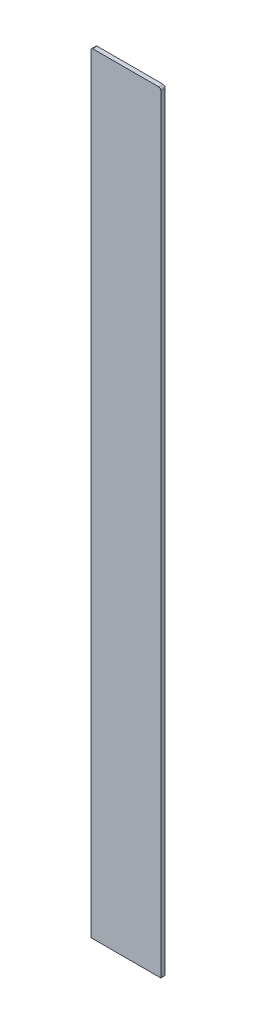
from build123d import *

# Parameters (mm, degrees)
SKETCH1_W           = 1.25
SKETCH1_H           = 80
BOSS_EXTRUDE1_DEPTH = 0.105
FILLET1_R           = 0.25
BOSS_EXTRUDE2_DEPTH = 0.2
BOSS_EXTRUDE3_DEPTH = 0.2


with BuildPart() as part:
    # Sketch1 → Boss-Extrude1 (new body)
    with BuildSketch(Plane.XY):
        with Locations((3.375, -44)):
            Rectangle(SKETCH1_W, SKETCH1_H)
        Polygon((-2.75, -4), (-2.75, -2.75), (-2.75, 2.75), (2.75, 2.75), (2.75, -2.75), (2.75, -4), (4, -4), (4, 4), (-4, 4), (-4, -4), align=None)
        with Locations((-3.375, -44)):
            Rectangle(SKETCH1_W, SKETCH1_H)
    extrude(amount=BOSS_EXTRUDE1_DEPTH)

    # Fillet1
    fillet1_edges = [part.edges().sort_by_distance(p)[0] for p in [
        (2.75, 2.75, 0.0525),
        (-2.75, 2.75, 0.0525),
        (-4, 4, 0.0525),
        (4, 4, 0.0525),
    ]]
    fillet(fillet1_edges, radius=FILLET1_R)

    # Sketch2 → Boss-Extrude2 (add)
    with BuildSketch(Plane(origin=(0, 0, 0), x_dir=(-1, 0, 0), z_dir=(0, 0, -1))):
        with BuildLine():
            Line((2.75, -84), (4, -84))
            Line((4, -84), (4, 3.75))
            ThreePointArc((4, 3.75), (3.926776695, 3.926776695), (3.75, 4))
            Line((3.75, 4), (-3.75, 4))
            ThreePointArc((-3.75, 4), (-3.926776695, 3.926776695), (-4, 3.75))
            Line((-4, 3.75), (-4, -84))
            Line((-4, -84), (-2.75, -84))
            Line((-2.75, -84), (-2.75, 2.5))
            ThreePointArc((-2.75, 2.5), (-2.676776695, 2.676776695), (-2.5, 2.75))
            Line((-2.5, 2.75), (2.5, 2.75))
            ThreePointArc((2.5, 2.75), (2.676776695, 2.676776695), (2.75, 2.5))
            Line((2.75, 2.5), (2.75, -84))
        make_face()
        with BuildLine():
            Line((-2.75, -84), (2.75, -84))
            Line((2.75, -84), (2.75, 2.5))
            ThreePointArc((2.75, 2.5), (2.676776695, 2.676776695), (2.5, 2.75))
            Line((2.5, 2.75), (-2.5, 2.75))
            ThreePointArc((-2.5, 2.75), (-2.676776695, 2.676776695), (-2.75, 2.5))
            Line((-2.75, 2.5), (-2.75, -84))
        make_face()
    extrude(amount=BOSS_EXTRUDE2_DEPTH)

    # Sketch4 → Boss-Extrude3 (add)
    with BuildSketch(Plane.XY.offset(0.105)):
        with BuildLine():
            ThreePointArc((4, 3.75), (3.926776695, 3.926776695), (3.75, 4))
            Line((3.75, 4), (-3.75, 4))
            ThreePointArc((-3.75, 4), (-3.926776695, 3.926776695), (-4, 3.75))
            Line((-4, 3.75), (-4, -84))
            Line((-4, -84), (-2.75, -84))
            Line((-2.75, -84), (-2.75, 2.5))
            ThreePointArc((-2.75, 2.5), (-2.676776695, 2.676776695), (-2.5, 2.75))
            Line((-2.5, 2.75), (2.5, 2.75))
            ThreePointArc((2.5, 2.75), (2.676776695, 2.676776695), (2.75, 2.5))
            Line((2.75, 2.5), (2.75, -84))
            Line((2.75, -84), (4, -84))
            Line((4, -84), (4, 3.75))
        make_face()
        with BuildLine():
            Line((-2.75, -84), (2.75, -84))
            Line((2.75, -84), (2.75, 2.5))
            ThreePointArc((2.75, 2.5), (2.676776695, 2.676776695), (2.5, 2.75))
            Line((2.5, 2.75), (-2.5, 2.75))
            ThreePointArc((-2.5, 2.75), (-2.676776695, 2.676776695), (-2.75, 2.5))
            Line((-2.75, 2.5), (-2.75, -84))
        make_face()
    extrude(amount=BOSS_EXTRUDE3_DEPTH)


solid = part.part
